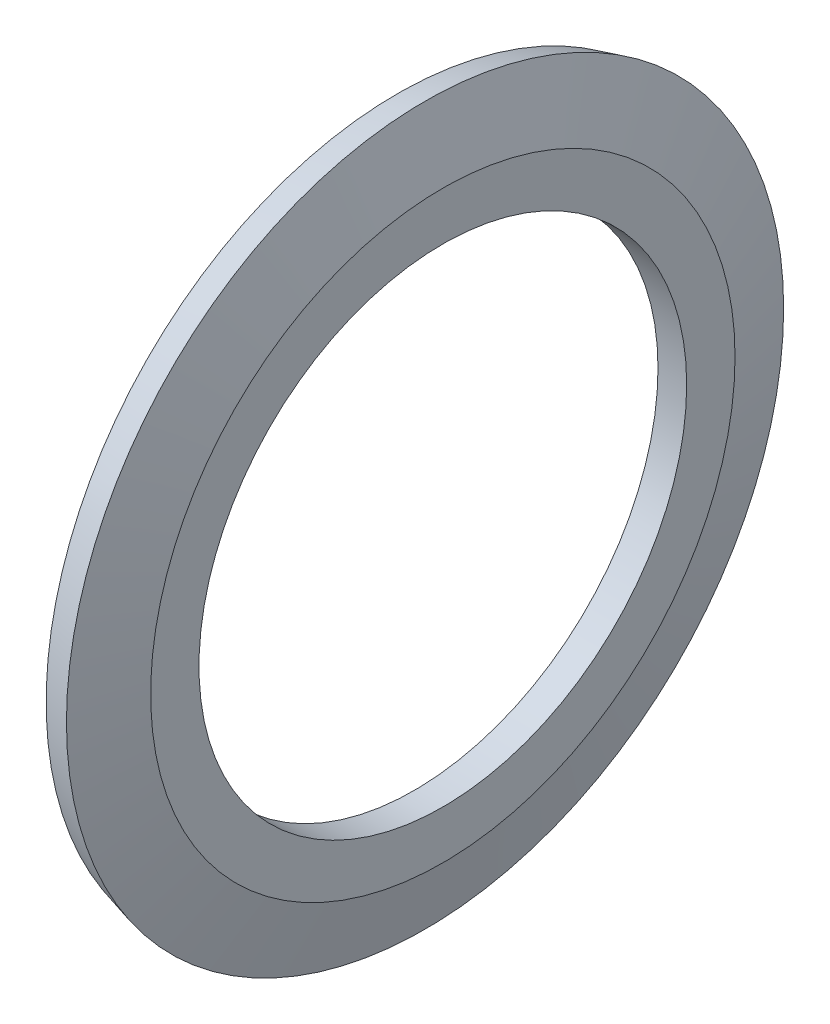
from build123d import *


with BuildPart() as part:
    # Sketch1 → Revolve1 (revolve)
    with BuildSketch(Plane.XY):
        Polygon((0, 8.5), (1, 8.5), (1, 10.185), (0.37969762, 12.5), (-0.586228207, 12.241180955), (0, 10.053347502), align=None)
    revolve(axis=Axis((1, 0, 0), (-1, 0, 0)))


solid = part.part
